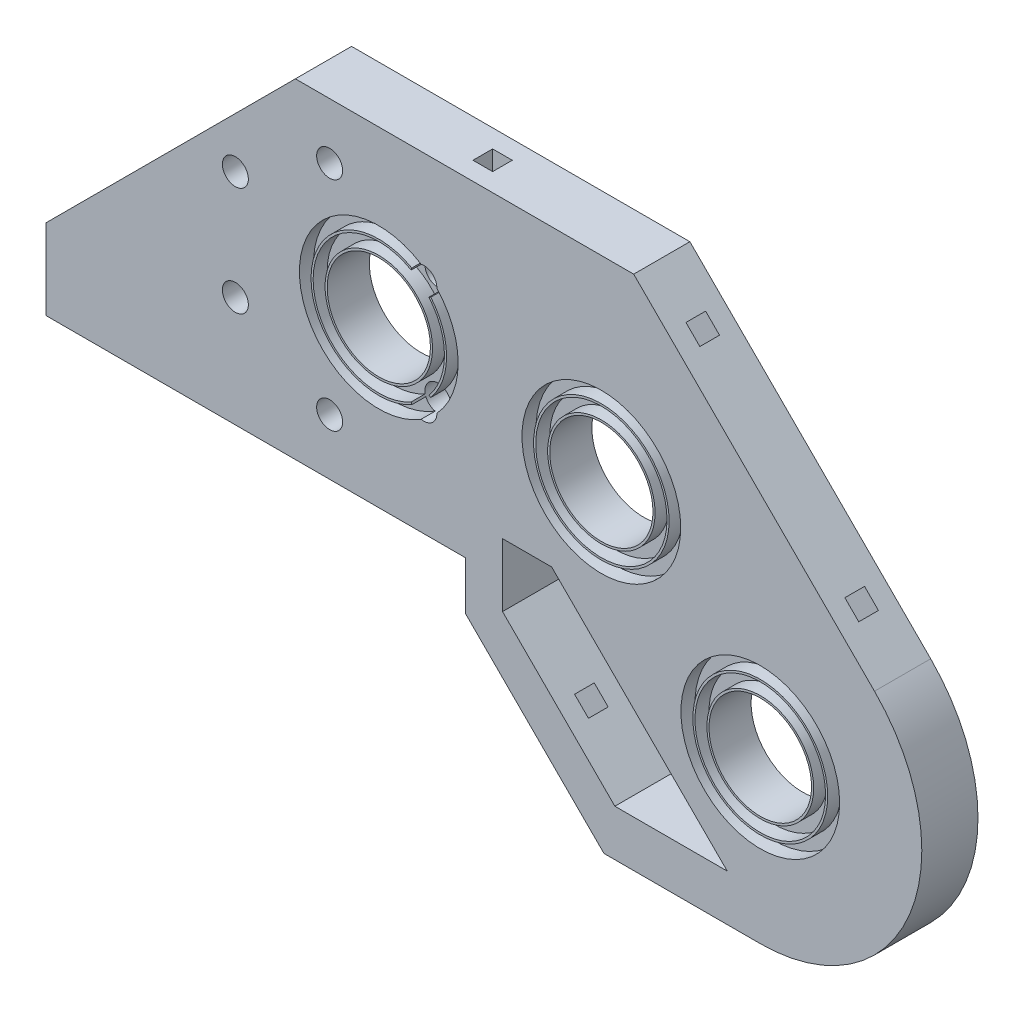
from build123d import *

# Parameters (mm, degrees)
MODEL_R                  = 7.35
MODEL_R_2                = 7.3
MODEL_R_3                = 1.85
RESSALTO_EXTRUS_O1_DEPTH = 8
ESBO_O3_R                = 11.3
CORTE_EXTRUS_O1_DEPTH    = 2
ESBO_O4_R                = 11.3
CORTE_EXTRUS_O2_DEPTH    = 2
ESBO_O2_R                = 3.3
CORTE_EXTRUS_O4_DEPTH    = 2
ESBO_O7_W                = 2.8
ESBO_O7_H                = 2.8
CORTE_EXTRUS_O6_DEPTH    = 6
ESBO_O8_W                = 2.8
ESBO_O8_H                = 2.8
CORTE_EXTRUS_O7_DEPTH    = 6
ESBO_O10_W               = 2.8
ESBO_O10_H               = 2.8
CORTE_EXTRUS_O9_DEPTH    = 6
ESBO_O11_R               = 7.65
ESBO_O11_R_2             = 7.35
ESBO_O11_R_3             = 9.65
ESBO_O11_R_4             = 9.35
ESBO_O11_R_5             = 9.6
ESBO_O11_R_6             = 9.3
ESBO_O11_R_7             = 7.6
ESBO_O11_R_8             = 7.3
RESSALTO_EXTRUS_O2_DEPTH = 2
RESSALTO_EXTRUS_O3_DEPTH = 8
ESBO_O6_R                = 1.5
CORTE_EXTRUS_O5_DEPTH    = 10


with BuildPart() as part:
    # Model → Ressalto-extrusão1 (new body)
    with BuildSketch(Plane.XY):
        with BuildLine():
            Line((0, 0), (39, 0))
            Line((39, 0), (39.7, 0))
            Line((39.7, 0), (39.7, -6.854833996))
            Line((39.7, -6.854833996), (52.445166004, -19.6))
            Line((52.445166004, -19.6), (59.445166004, -26.6))
            Line((59.445166004, -26.6), (81.699998871, -26.6))
            ThreePointArc((81.699998871, -26.6), (102.949229032, -12.401719466), (97.963455967, 12.663455967))
            Line((97.963455967, 12.663455967), (63.677897161, 46.949014774))
            Line((63.677897161, 46.949014774), (50.111140335, 46.949014774))
            Line((50.111140335, 46.949014774), (15.50707852, 46.949014774))
            Line((15.50707852, 46.949014774), (0, 31.441936254))
            Line((0, 31.441936254), (0, 0))
        make_face()
        with Locations((59.072583002, 19.027416998)):
            Circle(MODEL_R, mode=Mode.SUBTRACT)
        with Locations((81.7, -3.6)):
            Circle(MODEL_R_2, mode=Mode.SUBTRACT)
        with Locations((6.960594046, 15.730973227)):
            Circle(MODEL_R_3, mode=Mode.SUBTRACT)
        with Locations((6.960594046, 31.230973227)):
            Circle(MODEL_R_3, mode=Mode.SUBTRACT)
        with Locations((20.383987804, 38.980973227)):
            Circle(MODEL_R_3, mode=Mode.SUBTRACT)
        with Locations((33.807381563, 31.230973227)):
            Circle(MODEL_R_3, mode=Mode.SUBTRACT)
        with Locations((33.807381563, 15.730973227)):
            Circle(MODEL_R_3, mode=Mode.SUBTRACT)
        with Locations((20.383987804, 7.980973227)):
            Circle(MODEL_R_3, mode=Mode.SUBTRACT)
        with Locations((27.383987804, 23.480973227)):
            Circle(MODEL_R, mode=Mode.SUBTRACT)
        Polygon((72, -15), (52, 5), (45, 5), (45, -4), (61, -20), (77, -20), align=None, mode=Mode.SUBTRACT)
    extrude(amount=RESSALTO_EXTRUS_O1_DEPTH)

    # Esboço3 → Corte-extrusão1 (cut)
    with BuildSketch(Plane.XY):
        with Locations((81.7, -3.6)):
            Circle(ESBO_O3_R)
        with Locations((59.0726, 19.0274)):
            Circle(ESBO_O3_R)
        with Locations((27.384004802, 23.480956229)):
            Circle(ESBO_O3_R)
    extrude(amount=CORTE_EXTRUS_O1_DEPTH, mode=Mode.SUBTRACT)

    # Esboço4 → Corte-extrusão2 (cut)
    with BuildSketch(Plane.XY.offset(8)):
        with Locations((81.7, -3.6)):
            Circle(ESBO_O4_R)
        with Locations((59.0726, 19.0274)):
            Circle(ESBO_O4_R)
        with Locations((27.384004802, 23.480956229)):
            Circle(ESBO_O4_R)
    extrude(amount=-CORTE_EXTRUS_O2_DEPTH, mode=Mode.SUBTRACT)

    # Esboço2 → Corte-extrusão4 (cut)
    with BuildSketch(Plane.XY):
        with Locations((6.960594802, 15.730956229)):
            Circle(ESBO_O2_R)
        with Locations((6.960594802, 31.230956229)):
            Circle(ESBO_O2_R)
        with Locations((33.807404802, 15.730956229)):
            Circle(ESBO_O2_R)
        with Locations((20.384004802, 38.980956229)):
            Circle(ESBO_O2_R)
        with Locations((33.807404802, 31.230956229)):
            Circle(ESBO_O2_R)
        with Locations((20.384004802, 7.980976229)):
            Circle(ESBO_O2_R)
    extrude(amount=CORTE_EXTRUS_O4_DEPTH, mode=Mode.SUBTRACT)

    # Esboço7 → Corte-extrusão6 (cut)
    with BuildSketch(Plane(origin=(55.313455967, 55.313455967, 0), x_dir=(0, 0, -1), z_dir=(0.7071067811865474, 0.7071067811865477, 0))):
        with Locations((-4, -52.072657306)):
            Rectangle(ESBO_O7_W, ESBO_O7_H)
        with Locations((-4, -20.072657306)):
            Rectangle(ESBO_O7_W, ESBO_O7_H)
    extrude(amount=-CORTE_EXTRUS_O6_DEPTH, mode=Mode.SUBTRACT)

    # Esboço8 → Corte-extrusão7 (cut)
    with BuildSketch(Plane(origin=(0, 46.949014774, 0), x_dir=(1, 0, 0), z_dir=(0, 1, 0))):
        with Locations((39.59248784, -4)):
            Rectangle(ESBO_O8_W, ESBO_O8_H)
    extrude(amount=-CORTE_EXTRUS_O7_DEPTH, mode=Mode.SUBTRACT)

    # Esboço10 → Corte-extrusão9 (cut)
    with BuildSketch(Plane(origin=(16.422583002, 16.422583002, 0), x_dir=(0, 0, 1), z_dir=(-0.7071067811865477, -0.7071067811865475, 0))):
        with Locations((4, -46.881179593)):
            Rectangle(ESBO_O10_W, ESBO_O10_H)
    extrude(amount=-CORTE_EXTRUS_O9_DEPTH, mode=Mode.SUBTRACT)

    # Esboço11 → Ressalto-extrusão2 (add)
    with BuildSketch(Plane.XY.offset(6)):
        with BuildLine():
            ThreePointArc((34.519218365, 29.523405258), (36.162851789, 26.698743748), (36.733987804, 23.480973227))
            ThreePointArc((36.733987804, 23.480973227), (36.162851789, 20.263202705), (34.519218365, 17.438541195))
            ThreePointArc((34.519218365, 17.438541195), (34.658656459, 17.373480777), (34.792205686, 17.297057977))
            ThreePointArc((34.792205686, 17.297057977), (36.456247792, 20.192113437), (37.033987804, 23.480973227))
            ThreePointArc((37.033987804, 23.480973227), (36.456247792, 26.769833017), (34.792205686, 29.664888476))
            ThreePointArc((34.792205686, 29.664888476), (34.658656459, 29.588465677), (34.519218365, 29.523405258))
        make_face()
        with BuildLine():
            ThreePointArc((31.997376327, 15.348375466), (18.033987804, 23.480973227), (31.997376327, 31.613570987))
            ThreePointArc((31.997376327, 31.613570987), (32.03543104, 31.762660488), (32.085743581, 31.908071934))
            ThreePointArc((32.085743581, 31.908071934), (17.733987804, 23.480973227), (32.085743581, 15.05387452))
            ThreePointArc((32.085743581, 15.05387452), (32.03543104, 15.199285965), (31.997376327, 15.348375466))
        make_face()
        with Locations((27.383987804, 23.480973227)):
            Circle(ESBO_O11_R)
        with Locations((27.383987804, 23.480973227)):
            Circle(ESBO_O11_R_2, mode=Mode.SUBTRACT)
        with Locations((59.072583002, 19.027416998)):
            Circle(ESBO_O11_R_3)
        with Locations((59.072583002, 19.027416998)):
            Circle(ESBO_O11_R_4, mode=Mode.SUBTRACT)
        with Locations((59.072583002, 19.027416998)):
            Circle(ESBO_O11_R)
        with Locations((59.072583002, 19.027416998)):
            Circle(ESBO_O11_R_2, mode=Mode.SUBTRACT)
        with Locations((81.7, -3.6)):
            Circle(ESBO_O11_R_5)
        with Locations((81.7, -3.6)):
            Circle(ESBO_O11_R_6, mode=Mode.SUBTRACT)
        with Locations((81.7, -3.6)):
            Circle(ESBO_O11_R_7)
        with Locations((81.7, -3.6)):
            Circle(ESBO_O11_R_8, mode=Mode.SUBTRACT)
    extrude(amount=RESSALTO_EXTRUS_O2_DEPTH)

    # Esboço13 → Ressalto-extrusão3 (add)
    with BuildSketch(Plane.XY.offset(8)):
        Polygon((0, 31.441936254), (-20, 11.441936254), (-20, 0), (0, 0), align=None)
    extrude(amount=-RESSALTO_EXTRUS_O3_DEPTH)

    # Esboço6 → Corte-extrusão5 (cut)
    with BuildSketch(Plane.XZ):
        with Locations(Location((4.7, 4, 0), (0, 0, 270))):
            Circle(ESBO_O6_R)
        with Locations(Location((23.7, 4, 0), (0, 0, 270))):
            Circle(ESBO_O6_R)
        with Locations(Location((-14.3, 4, 0), (0, 0, 270))):
            Circle(ESBO_O6_R)
    extrude(amount=-CORTE_EXTRUS_O5_DEPTH, mode=Mode.SUBTRACT)


solid = part.part
